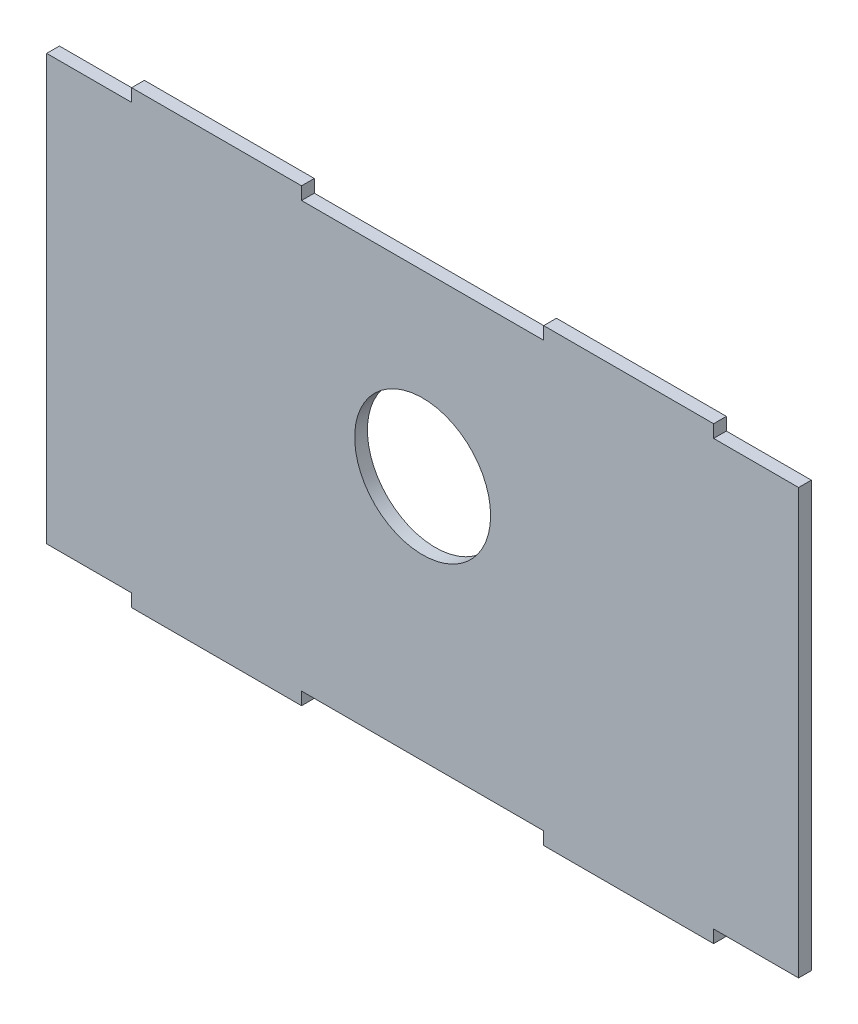
from build123d import *

# Parameters (mm, degrees)
SKETCH1_R           = 16
BOSS_EXTRUDE1_DEPTH = 1.5


with BuildPart() as part:
    # Sketch1 → Boss-Extrude1 (new body, symmetric)
    with BuildSketch(Plane.XY):
        Polygon((-28.5, 50), (28.5, 50), (28.5, 53), (68.5, 53), (68.5, 50), (88.5, 50), (88.5, -50), (68.5, -50), (68.5, -53), (28.5, -53), (28.5, -50), (-28.5, -50), (-28.5, -53), (-68.5, -53), (-68.5, -50), (-88.5, -50), (-88.5, 50), (-68.5, 50), (-68.5, 53), (-28.5, 53), align=None)
        with Locations((0, 8)):
            Circle(SKETCH1_R, mode=Mode.SUBTRACT)
    extrude(amount=BOSS_EXTRUDE1_DEPTH, both=True)


solid = part.part
